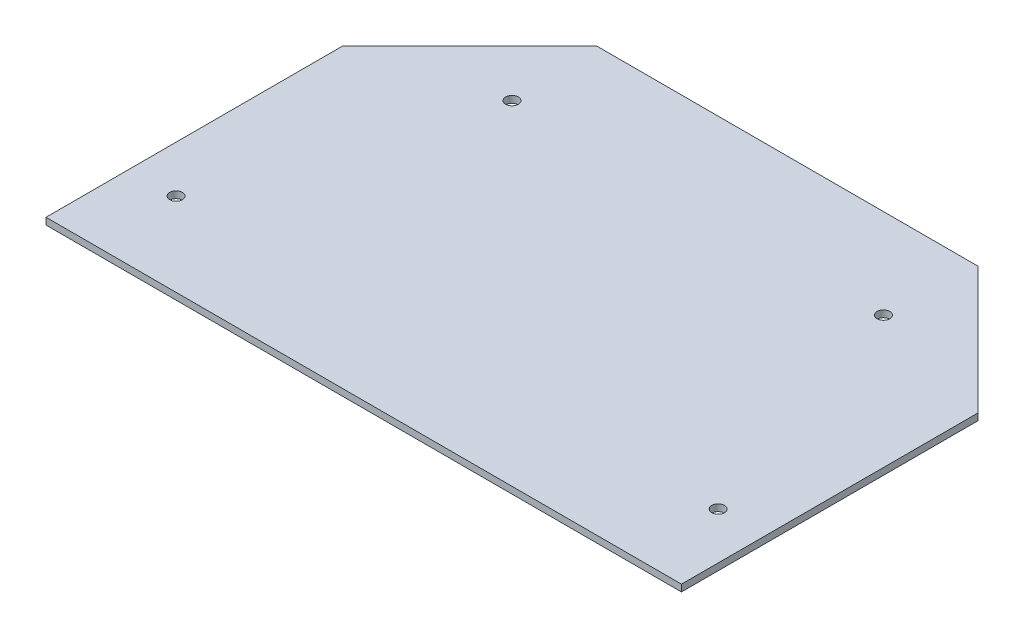
from build123d import *

# Parameters (mm, degrees)
SKETCH1_R           = 1.5
BOSS_EXTRUDE1_DEPTH = 1.6


with BuildPart() as part:
    # Sketch1 → Boss-Extrude1 (new body)
    with BuildSketch(Plane(origin=(0, 0, 0), x_dir=(1, 0, 0), z_dir=(0, 1, 0))):
        Polygon((-75, -35), (-75, 35), (-45, 65), (0, 65), (0, -35), align=None)
        with Locations((-43.840620434, 43.840620434)):
            Circle(SKETCH1_R, mode=Mode.SUBTRACT)
        with Locations((-63.979633983, -15.316867676)):
            Circle(SKETCH1_R, mode=Mode.SUBTRACT)
    boss_extrude1 = extrude(amount=BOSS_EXTRUDE1_DEPTH)

    # Mirror1: Boss-Extrude1 across plane
    add(boss_extrude1.mirror(Plane(origin=(0, 1.6, 35), x_dir=(0, 0, 1), z_dir=(-1, 0, 0))))


solid = part.part
